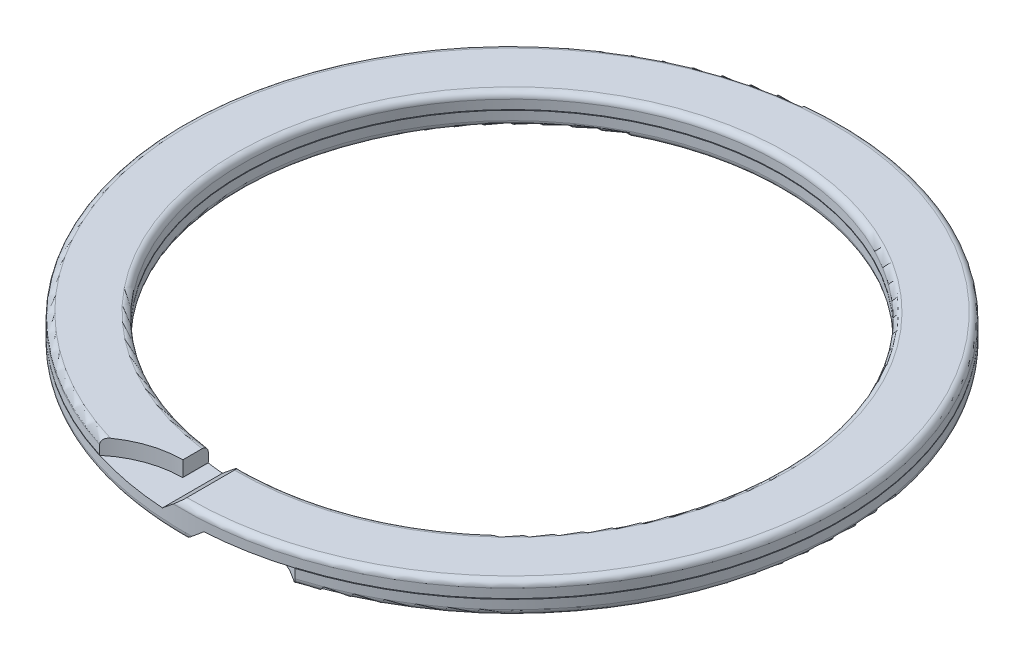
from build123d import *

# Parameters (mm, degrees)
CUT_EXTRUDE1_DEPTH      = 21
CUT_EXTRUDE2_DEPTH      = 21
CUT_EXTRUDE3_DEPTH      = 21
CUT_EXTRUDE4_DEPTH      = 21
CUT_EXTRUDE5_DEPTH      = 0.01
CUT_EXTRUDE5_DEPTH_BACK = 0.01


with BuildPart() as part:
    # Sketch1 → Revolve1 (revolve)
    with BuildSketch(Plane(origin=(0, 0, 0), x_dir=(0, 0, -1), z_dir=(1, 0, 0)), mode=Mode.PRIVATE) as revolve1_sk:
        with BuildLine():
            Line((8.788, -0.495), (10.302, -0.495))
            ThreePointArc((10.302, -0.495), (10.442007143, -0.437007143), (10.5, -0.297))
            Line((10.5, -0.297), (10.5, 0.297))
            ThreePointArc((10.5, 0.297), (10.442007143, 0.437007143), (10.302, 0.495))
            Line((10.302, 0.495), (8.788, 0.495))
            ThreePointArc((8.788, 0.495), (8.647992857, 0.437007143), (8.59, 0.297))
            Line((8.59, 0.297), (8.59, -0.297))
            ThreePointArc((8.59, -0.297), (8.647992857, -0.437007143), (8.788, -0.495))
        make_face()
    revolve(revolve1_sk.sketch.rotate(Axis((0, -1, 0), (0, 1, 0)), 180), axis=Axis((0, -1, 0), (0, 1, 0)))

    # Sketch2 → Cut-Extrude1 (cut)
    with BuildSketch(Plane(origin=(0, 0, 0), x_dir=(1, 0, 0), z_dir=(0, 1, 0))):
        with BuildLine():
            Line((-1.165666667, -15.369150396), (-1.165666667, -9.320817394))
            ThreePointArc((-1.165666667, -9.320817394), (-4.189833168, -12.344983895), (-1.165666667, -15.369150396))
        make_face()
    extrude(amount=CUT_EXTRUDE1_DEPTH, mode=Mode.SUBTRACT)

    # Sketch3 → Cut-Extrude2 (cut)
    with BuildSketch(Plane(origin=(0, 0, 0), x_dir=(1, 0, 0), z_dir=(0, 1, 0))):
        with BuildLine():
            Line((1.165666667, -9.320817394), (1.165666667, -15.369150396))
            ThreePointArc((1.165666667, -15.369150396), (4.189833168, -12.344983895), (1.165666667, -9.320817394))
        make_face()
    extrude(amount=-CUT_EXTRUDE2_DEPTH, mode=Mode.SUBTRACT)

    # Sketch4 → Cut-Extrude3 (cut)
    with BuildSketch(Plane.XY):
        Polygon((-1.166666667, 1.0885), (-1.166666667, 0), (-0.659393939, 0), (0.66, 1.0885), align=None)
    extrude(amount=CUT_EXTRUDE3_DEPTH, mode=Mode.SUBTRACT)

    # Sketch5 → Cut-Extrude4 (cut)
    with BuildSketch(Plane.XY):
        Polygon((-0.66, -1.0885), (1.166666667, -1.0885), (1.166666667, 0), (0.659393939, 0), align=None)
    extrude(amount=CUT_EXTRUDE4_DEPTH, mode=Mode.SUBTRACT)

    # Sketch6 → Cut-Extrude5 (cut, two sides)
    with BuildSketch(Plane(origin=(0, 0, 0), x_dir=(1, 0, 0), z_dir=(0, 1, 0))) as cut_extrude5_sk:
        with BuildLine():
            Line((-10.71, -10.71), (-3.710760158, -10.71))
            ThreePointArc((-3.710760158, -10.71), (-2.615558728, -9.690497914), (-1.165666667, -9.320817394))
            Line((-1.165666667, -9.320817394), (-1.165666667, -8.500448295))
            ThreePointArc((-1.165666667, -8.500448295), (0, -8.58), (1.165666667, -8.500448295))
            Line((1.165666667, -8.500448295), (1.165666667, -9.320817394))
            ThreePointArc((1.165666667, -9.320817394), (2.615558728, -9.690497914), (3.710760158, -10.71))
            Line((3.710760158, -10.71), (10.71, -10.71))
            Line((10.71, -10.71), (10.71, 10.71))
            Line((10.71, 10.71), (-10.71, 10.71))
            Line((-10.71, 10.71), (-10.71, -10.71))
        make_face()
    extrude(amount=CUT_EXTRUDE5_DEPTH, mode=Mode.SUBTRACT)
    extrude(cut_extrude5_sk.sketch, amount=-CUT_EXTRUDE5_DEPTH_BACK, mode=Mode.SUBTRACT)


solid = part.part
